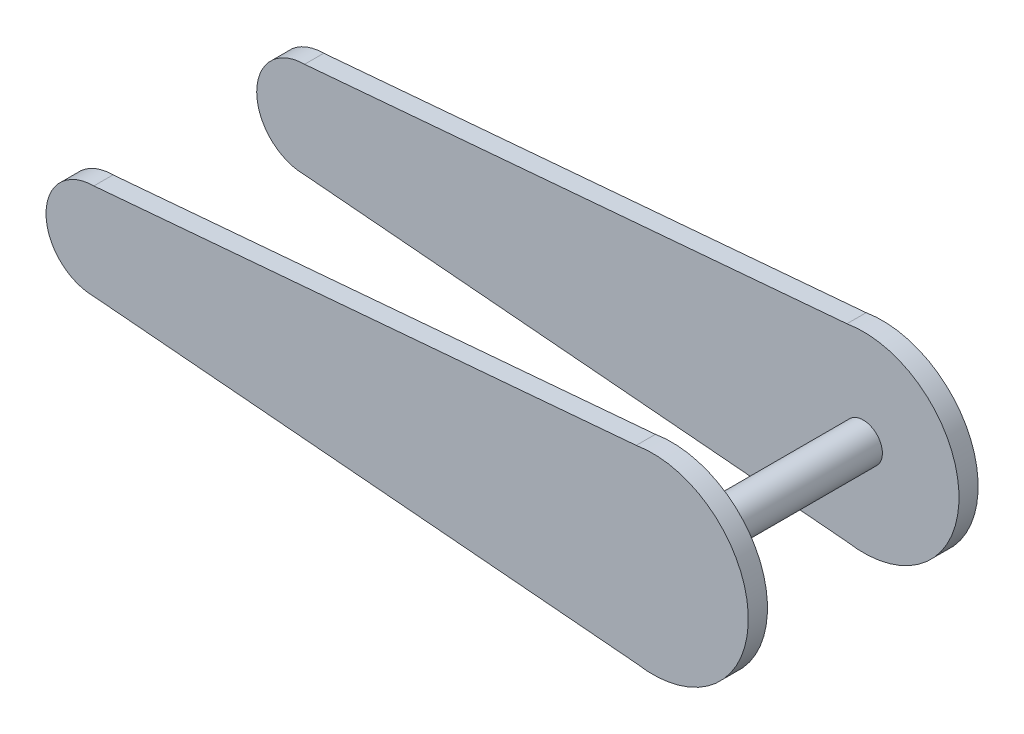
from build123d import *

# Parameters (mm, degrees)
CROQUIS1_R              = 3
SALIENTE_EXTRUIR1_DEPTH = 18
CROQUIS2_R              = 3
SALIENTE_EXTRUIR2_DEPTH = 18
SALIENTE_EXTRUIR3_DEPTH = 15
CROQUIS4_W              = 3
CROQUIS4_H              = 30
SALIENTE_EXTRUIR4_DEPTH = 95
CORTAR_EXTRUIR1_DEPTH   = 95


with BuildPart() as part:
    # Croquis1 → Saliente-Extruir1 (new body)
    with BuildSketch(Plane.XY):
        Circle(CROQUIS1_R)
    extrude(amount=SALIENTE_EXTRUIR1_DEPTH)

    # Croquis2 → Saliente-Extruir2 (add)
    with BuildSketch(Plane.XY):
        Circle(CROQUIS2_R)
    extrude(amount=-SALIENTE_EXTRUIR2_DEPTH)

    # Croquis3 → Saliente-Extruir3 (add)
    with BuildSketch(Plane(origin=(0, 0, 0), x_dir=(0, 0, -1), z_dir=(1, 0, 0))):
        Polygon((-18, -15), (-18, 0), (-18, 15), (-15, 15), (-15, -15), align=None)
        Polygon((18, 0), (18, 15), (15, 15), (15, -15), (18, -15), align=None)
    extrude(amount=SALIENTE_EXTRUIR3_DEPTH)

    # Croquis4 → Saliente-Extruir4 (add)
    with BuildSketch(Plane(origin=(0, 0, 0), x_dir=(0, 0, -1), z_dir=(1, 0, 0))):
        with Locations((16.5, 0)):
            Rectangle(CROQUIS4_W, CROQUIS4_H)
        with Locations((-16.5, 0)):
            Rectangle(CROQUIS4_W, CROQUIS4_H)
    extrude(amount=-SALIENTE_EXTRUIR4_DEPTH)

    # Croquis5 → Cortar-Extruir1 (cut)
    with BuildSketch(Plane.XY.offset(18)):
        with BuildLine():
            ThreePointArc((-95, 0), (-92.803300859, 5.303300859), (-87.5, 7.5))
            Line((-87.5, 7.5), (-2.55267423, 14.781199352))
            ThreePointArc((-2.55267423, 14.781199352), (-1.28101712, 14.945199736), (0, 15))
            Line((0, 15), (-95, 15))
            Line((-95, 15), (-95, 0))
        make_face()
        with BuildLine():
            ThreePointArc((-87.5, -7.5), (-92.803300859, -5.303300859), (-95, 0))
            Line((-95, 0), (-95, -15))
            Line((-95, -15), (0, -15))
            ThreePointArc((0, -15), (-1.28101712, -14.945199736), (-2.55267423, -14.781199352))
            Line((-2.55267423, -14.781199352), (-87.5, -7.5))
        make_face()
        with BuildLine():
            Line((15, -15), (15, 0))
            ThreePointArc((15, 0), (10.606601718, -10.606601718), (0, -15))
            Line((0, -15), (15, -15))
        make_face()
        with BuildLine():
            Line((15, 15), (0, 15))
            ThreePointArc((0, 15), (10.606601718, 10.606601718), (15, 0))
            Line((15, 0), (15, 15))
        make_face()
    extrude(amount=-CORTAR_EXTRUIR1_DEPTH, mode=Mode.SUBTRACT)


solid = part.part
